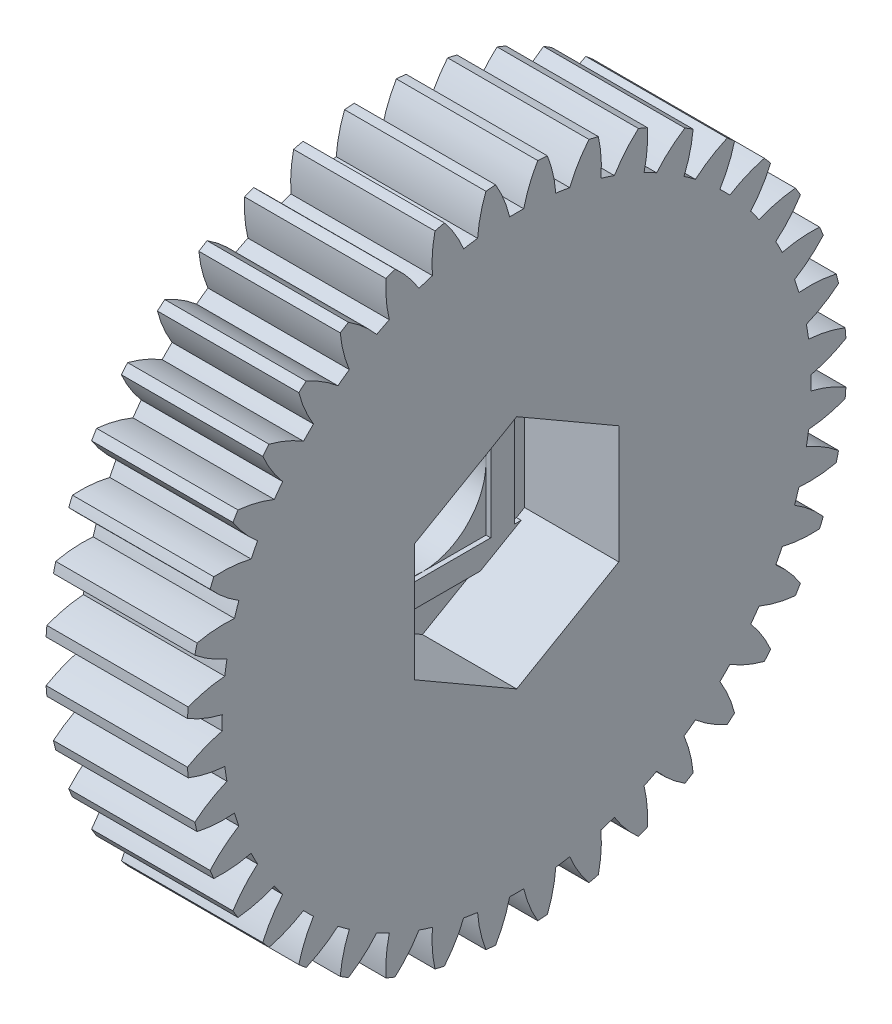
from build123d import *

# Parameters (mm, degrees)
BASPROSKE_W         = 9
BASPROSKE_H         = 21
TOOTHCUT_DEPTH      = 32.032241298
TEETHCUTS_COUNT     = 40
TEETHCUTS_ANGLE     = 351
BORSKE_R            = 2
BORE_DEPTH          = 50.0000508
CUT_EXTRUDE1_DEPTH  = 6
SKETCH1_7_R         = 4.05
CUT_EXTRUDE2_DEPTH  = 31.974304622
SKETCH2_R           = 6.5
SKETCH2_R_2         = 4
BOSS_EXTRUDE1_DEPTH = 1.8
SKETCH3_W           = 8.1
SKETCH3_H           = 8.1
BOSS_EXTRUDE2_DEPTH = 0.3


with BuildPart() as part:
    # BasProSke → Base-Revolve (revolve)
    with BuildSketch(Plane(origin=(0, 0, 0), x_dir=(1, 0, 0), z_dir=(0, 1, 0))):
        with Locations((4.5, 10.5)):
            Rectangle(BASPROSKE_W, BASPROSKE_H)
    revolve(axis=Axis((-10, 0, 0), (1, 0, 0)))

    # TooCutSke → ToothCut (cut, through all)
    with BuildSketch(Plane(origin=(0, 0, 0), x_dir=(0, 0, -1), z_dir=(1, 0, 0))):
        with BuildLine():
            ThreePointArc((0.448673268, 18.74363074), (0, 18.749), (-0.448673268, 18.74363074))
            ThreePointArc((-0.448673268, 18.74363074), (-0.816786816, 19.89705013), (-1.354745081, 20.981708961))
            ThreePointArc((-1.354745081, 20.981708961), (0, 21.0254), (1.354745081, 20.981708961))
            ThreePointArc((1.354745081, 20.981708961), (0.816786816, 19.89705013), (0.448673268, 18.74363074))
        make_face()
    toothcut = extrude(amount=TOOTHCUT_DEPTH, mode=Mode.SUBTRACT)

    # TeethCuts: ToothCut ×40 about axis
    teethcuts_axis = Axis((-10, 0, 0), (1, 0, 0))
    for i in range(1, TEETHCUTS_COUNT):
        add(toothcut.rotate(teethcuts_axis, i * TEETHCUTS_ANGLE / (TEETHCUTS_COUNT - 1)), mode=Mode.SUBTRACT)

    # BorSke → Bore (cut, symmetric)
    with BuildSketch(Plane(origin=(0, 0, 0), x_dir=(0, 0, -1), z_dir=(1, 0, 0))):
        Circle(BORSKE_R)
    extrude(amount=BORE_DEPTH, both=True, mode=Mode.SUBTRACT)

    # Sketch1 → Cut-Extrude1 (cut)
    with BuildSketch(Plane(origin=(9, 0, 0), x_dir=(0, 0, -1), z_dir=(1, 0, 0))):
        Polygon((0, 7.505553499), (-6.5, 3.75277675), (-6.5, -3.75277675), (0, -7.505553499), (6.5, -3.75277675), (6.5, 3.75277675), align=None)
    extrude(amount=-CUT_EXTRUDE1_DEPTH, mode=Mode.SUBTRACT)

    # Sketch1_7 → Cut-Extrude2 (cut, through all)
    with BuildSketch(Plane(origin=(9, 0, 0), x_dir=(0, 0, -1), z_dir=(1, 0, 0))):
        Circle(SKETCH1_7_R)
    extrude(amount=-CUT_EXTRUDE2_DEPTH, mode=Mode.SUBTRACT)

    # Sketch2 → Boss-Extrude1 (add)
    with BuildSketch(Plane.ZY):
        Circle(SKETCH2_R)
        Circle(SKETCH2_R_2, mode=Mode.SUBTRACT)
    extrude(amount=BOSS_EXTRUDE1_DEPTH)

    # Sketch3 → Boss-Extrude2 (add)
    with BuildSketch(Plane(origin=(3, 0, 0), x_dir=(0, 0, -1), z_dir=(1, 0, 0))):
        Polygon((5.55, -4.05), (5.55, 4.05), (5.985194229, 4.05), (3.387118018, 5.55), (-3.387118018, 5.55), (-5.985194229, 4.05), (-5.55, 4.05), (-5.55, -4.05), (-5.985194229, -4.05), (-3.387118018, -5.55), (3.387118018, -5.55), (5.985194229, -4.05), align=None)
        Rectangle(SKETCH3_W, SKETCH3_H, mode=Mode.SUBTRACT)
    extrude(amount=BOSS_EXTRUDE2_DEPTH)


solid = part.part
